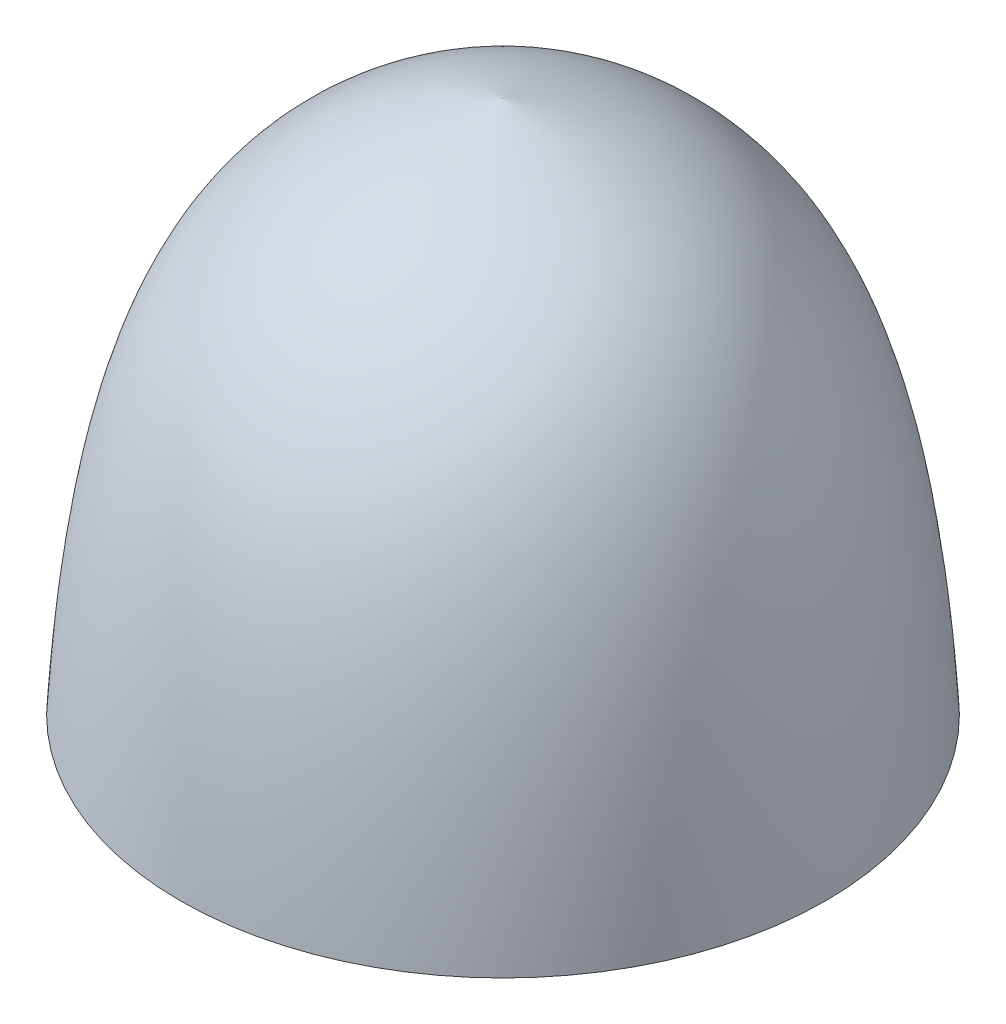
from build123d import *

# Parameters (mm, degrees)
SKETCH4_R          = 12.7
CUT_EXTRUDE1_DEPTH = 19.05


with BuildPart() as part:
    # Sketch1 → Revolve2 (revolve)
    with BuildSketch(Plane.XY):
        with BuildLine():
            Line((0, 0), (12.7, 0))
            Line((12.7, 0), (17.679751134, 0))
            add(Edge.make_bspline(
                [(17.679751134, 0), (16.48562501, 19.443458986), (12.125204967, 26.49238204), (0, 29.212974986)],
                knots=[0, 0, 0, 0, 1, 1, 1, 1], degree=3))
            Line((0, 29.212974986), (0, 19.05))
            Line((0, 19.05), (0, 0))
        make_face()
    revolve(axis=Axis((0, 0, 0), (0, 1, 0)))

    # Sketch4 → Cut-Extrude1 (cut)
    with BuildSketch(Plane.XZ):
        Circle(SKETCH4_R)
    extrude(amount=-CUT_EXTRUDE1_DEPTH, mode=Mode.SUBTRACT)


solid = part.part
